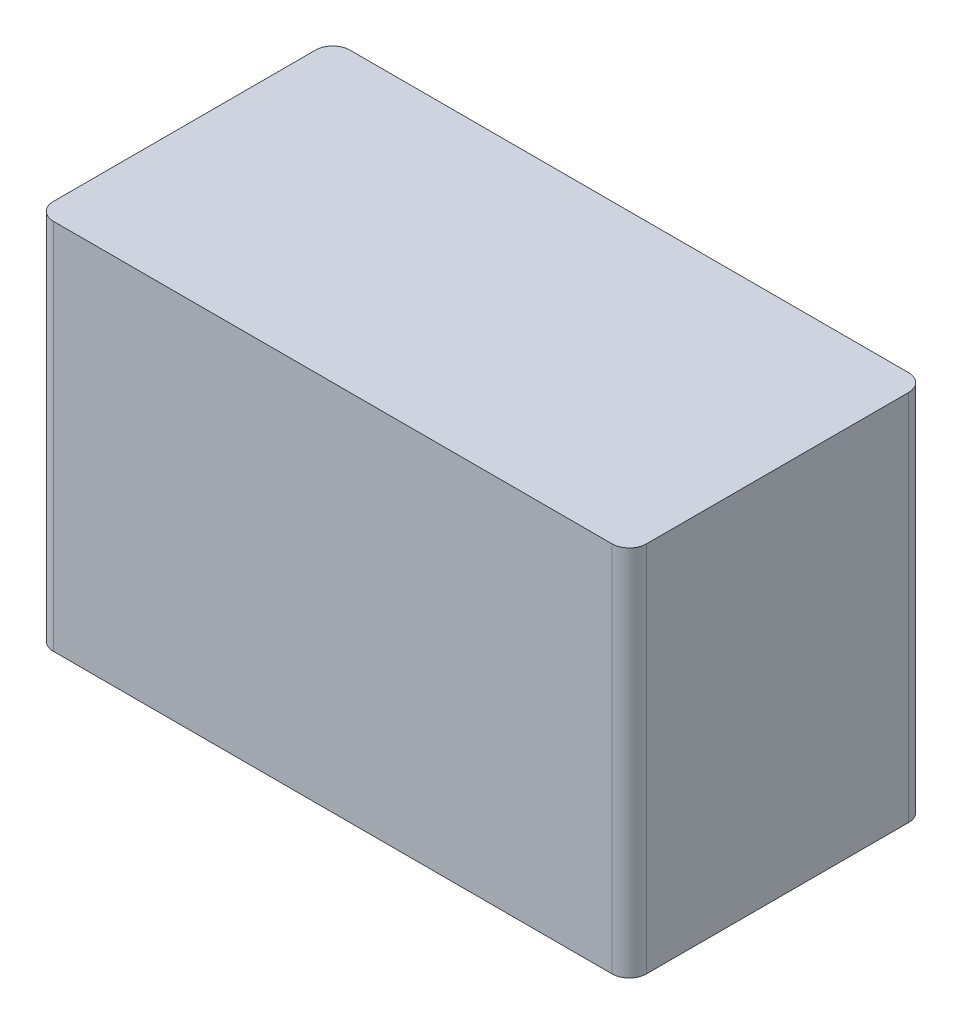
from build123d import *

# Parameters (mm, degrees)
CROQUIS1_W              = 41.4
CROQUIS1_H              = 20.7
SALIENTE_EXTRUIR1_DEPTH = 26
CROQUIS3_R              = 5.25
SALIENTE_EXTRUIR2_DEPTH = 1
REDONDEO1_R             = 0.4
CROQUIS5_R              = 4.35
CORTAR_EXTRUIR1_DEPTH   = 0.1
REDONDEO2_R             = 1.2


with BuildPart() as part:
    # Croquis1 → Saliente-Extruir1 (new body)
    with BuildSketch(Plane(origin=(0, 0, 0), x_dir=(1, 0, 0), z_dir=(0, 1, 0))):
        Rectangle(CROQUIS1_W, CROQUIS1_H)
    extrude(amount=SALIENTE_EXTRUIR1_DEPTH)

    # Croquis3 → Saliente-Extruir2 (add)
    with BuildSketch(Plane.ZY.offset(20.7)):
        with Locations((0, 10)):
            Circle(CROQUIS3_R)
    extrude(amount=SALIENTE_EXTRUIR2_DEPTH)

    # Redondeo1
    redondeo1_edges = [part.edges().sort_by_distance(p)[0] for p in [
        (-20.7, 10, -5.25),
        (-21.7, 10, -5.25),
    ]]
    fillet(redondeo1_edges, radius=REDONDEO1_R)

    # Croquis5 → Cortar-Extruir1 (cut)
    with BuildSketch(Plane.ZY.offset(21.7)):
        with Locations((0, 10)):
            Circle(CROQUIS5_R)
    extrude(amount=-CORTAR_EXTRUIR1_DEPTH, mode=Mode.SUBTRACT)

    # Redondeo2
    redondeo2_edges = [part.edges().sort_by_distance(p)[0] for p in [
        (20.7, 13, 10.35),
        (-20.7, 13, 10.35),
        (-20.7, 13, -10.35),
        (20.7, 13, -10.35),
    ]]
    fillet(redondeo2_edges, radius=REDONDEO2_R)


solid = part.part
